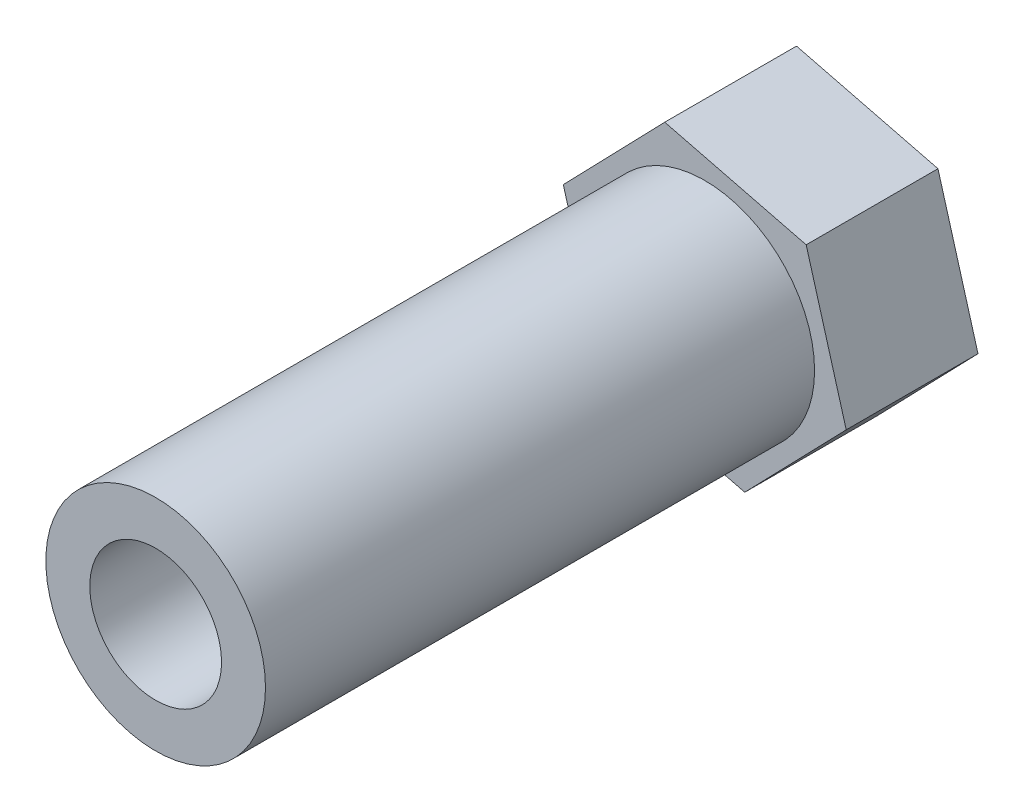
from build123d import *

# Parameters (mm, degrees)
SKETCH1_R           = 1.5
BOSS_EXTRUDE1_DEPTH = 6
SKETCH2_R           = 5
SKETCH2_R_2         = 3
BOSS_EXTRUDE2_DEPTH = 25


with BuildPart() as part:
    # Sketch1 → Boss-Extrude1 (new body)
    with BuildSketch(Plane.XY):
        Polygon((-6.440472633, 1.613581606), (-4.617638978, -4.77082211), (1.822833655, -6.384403715), (6.440472633, -1.613581606), (4.617638978, 4.77082211), (-1.822833655, 6.384403715), align=None)
        Circle(SKETCH1_R, mode=Mode.SUBTRACT)
    extrude(amount=BOSS_EXTRUDE1_DEPTH)

    # Sketch2 → Boss-Extrude2 (add)
    with BuildSketch(Plane.XY.offset(6)):
        Circle(SKETCH2_R)
        Circle(SKETCH2_R_2, mode=Mode.SUBTRACT)
    extrude(amount=BOSS_EXTRUDE2_DEPTH)


solid = part.part
